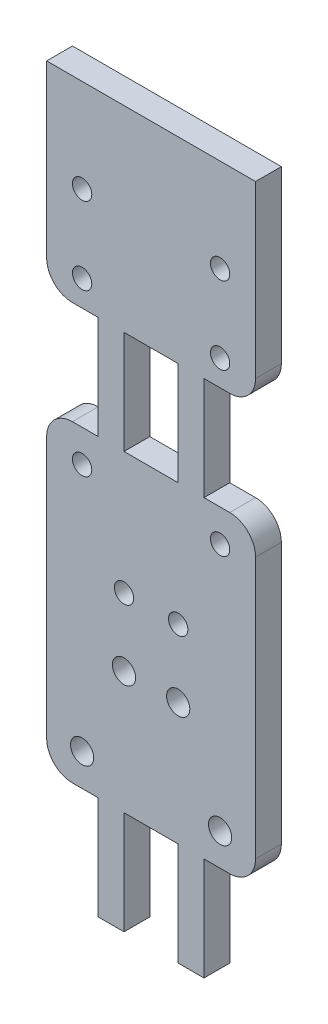
from build123d import *

# Parameters (mm, degrees)
SKETCH1_R           = 0.75
SKETCH1_R_2         = 0.9
SKETCH1_W           = 4.2
SKETCH1_H           = 8
BOSS_EXTRUDE1_DEPTH = 2


with BuildPart() as part:
    # Sketch1 → Boss-Extrude1 (new body)
    with BuildSketch(Plane.XY):
        with BuildLine():
            Line((4, 44.7), (4, 52.7))
            Line((4, 52.7), (2, 52.7))
            ThreePointArc((2, 52.7), (0.585786438, 53.285786438), (0, 54.7))
            Line((0, 54.7), (0, 67.93))
            Line((0, 67.93), (16.2, 67.93))
            Line((16.2, 67.93), (16.2, 54.7))
            ThreePointArc((16.2, 54.7), (15.614213562, 53.285786438), (14.2, 52.7))
            Line((14.2, 52.7), (12.2, 52.7))
            Line((12.2, 52.7), (12.2, 44.7))
            Line((12.2, 44.7), (14.2, 44.7))
            ThreePointArc((14.2, 44.7), (15.614213562, 44.114213562), (16.2, 42.7))
            Line((16.2, 42.7), (16.2, 22.44))
            ThreePointArc((16.2, 22.44), (15.614213562, 21.025786438), (14.2, 20.44))
            Line((14.2, 20.44), (12.2, 20.44))
            Line((12.2, 20.44), (12.2, 12.44))
            Line((12.2, 12.44), (10.2, 12.44))
            Line((10.2, 12.44), (10.2, 20.44))
            Line((10.2, 20.44), (6, 20.44))
            Line((6, 20.44), (6, 12.44))
            Line((6, 12.44), (4, 12.44))
            Line((4, 12.44), (4, 20.44))
            Line((4, 20.44), (2, 20.44))
            ThreePointArc((2, 20.44), (0.585786438, 21.025786438), (0, 22.44))
            Line((0, 22.44), (0, 42.7))
            ThreePointArc((0, 42.7), (0.585786438, 44.114213562), (2, 44.7))
            Line((2, 44.7), (4, 44.7))
        make_face()
        with Locations((2.75, 60.7)):
            Circle(SKETCH1_R, mode=Mode.SUBTRACT)
        with Locations((13.45, 54.7)):
            Circle(SKETCH1_R, mode=Mode.SUBTRACT)
        with Locations((13.45, 42.2)):
            Circle(SKETCH1_R, mode=Mode.SUBTRACT)
        with Locations((13.45, 22.94)):
            Circle(SKETCH1_R_2, mode=Mode.SUBTRACT)
        with Locations((10.2, 29.94)):
            Circle(SKETCH1_R_2, mode=Mode.SUBTRACT)
        with Locations((6, 35.2)):
            Circle(SKETCH1_R, mode=Mode.SUBTRACT)
        with Locations((13.45, 60.7)):
            Circle(SKETCH1_R, mode=Mode.SUBTRACT)
        with Locations((10.2, 35.2)):
            Circle(SKETCH1_R, mode=Mode.SUBTRACT)
        with Locations((6, 29.94)):
            Circle(SKETCH1_R_2, mode=Mode.SUBTRACT)
        with Locations((2.75, 22.94)):
            Circle(SKETCH1_R_2, mode=Mode.SUBTRACT)
        with Locations((2.75, 42.2)):
            Circle(SKETCH1_R, mode=Mode.SUBTRACT)
        with Locations((2.75, 54.7)):
            Circle(SKETCH1_R, mode=Mode.SUBTRACT)
        with Locations((8.1, 48.7)):
            Rectangle(SKETCH1_W, SKETCH1_H, mode=Mode.SUBTRACT)
    extrude(amount=BOSS_EXTRUDE1_DEPTH)


solid = part.part
